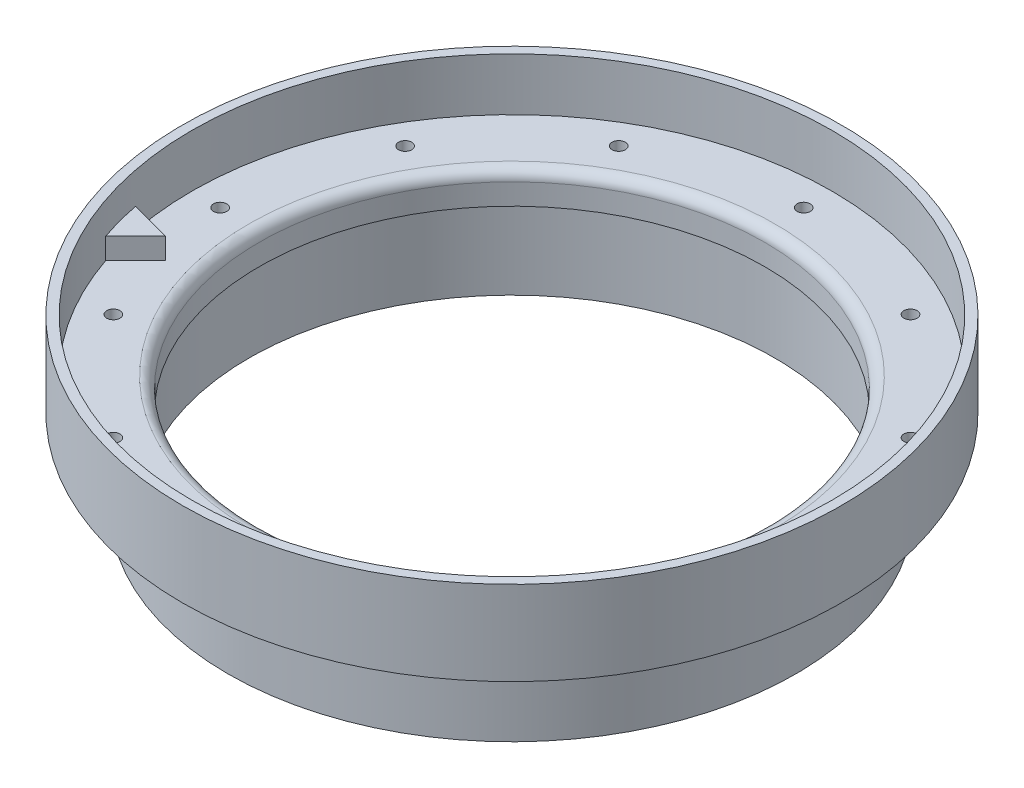
from build123d import *

# Parameters (mm, degrees)
F_3_48_TAPPED_HOLE1_D = 1.9939
CIRPATTERN1_COUNT     = 12
BOSS_EXTRUDE1_DEPTH   = 3.175


with BuildPart() as part:
    # Cross Section → Main (revolve)
    with BuildSketch(Plane.XY):
        with BuildLine():
            Line((-38.1, 0), (-38.1, -3.175))
            Line((-38.1, -3.175), (-39.6367, -3.175))
            Line((-39.6367, -3.175), (-39.6367, -15.875))
            Line((-39.6367, -15.875), (-42.8117, -15.875))
            Line((-42.8117, -15.875), (-42.8117, -3.175))
            Line((-42.8117, -3.175), (-49.6697, -3.175))
            Line((-49.6697, -3.175), (-49.6697, 9.525))
            Line((-49.6697, 9.525), (-48.26, 9.525))
            Line((-48.26, 9.525), (-48.26, 1.5875))
            Line((-48.26, 1.5875), (-39.6875, 1.5875))
            ThreePointArc((-39.6875, 1.5875), (-38.564967985, 1.122532015), (-38.1, 0))
        make_face()
    revolve(axis=Axis((0, 55, 0), (0, -1, 0)))

    # #3-48 Tapped Hole1 (through all)
    with Locations(Plane(origin=(0, 1.5875, 0), x_dir=(1, 0, 0), z_dir=(0, 1, 0))):
        with Locations((-43.97375, 0)):
            f_3_48_tapped_hole1 = Hole(F_3_48_TAPPED_HOLE1_D / 2)

    # CirPattern1: #3-48 Tapped Hole1 ×12 about axis
    cirpattern1_axis = Axis((0, 0, 0), (0, 1, 0))
    for i in range(1, CIRPATTERN1_COUNT):
        add(f_3_48_tapped_hole1.rotate(cirpattern1_axis, i * 360 / CIRPATTERN1_COUNT), mode=Mode.SUBTRACT)

    # Sketch3 → Boss-Extrude1 (add)
    with BuildSketch(Plane(origin=(0, 1.5875, 0), x_dir=(1, 0, 0), z_dir=(0, 1, 0))):
        with BuildLine():
            Line((-45.692838455, -15.530361037), (-41.202710394, -11.040232976))
            Line((-41.202710394, -11.040232976), (-47.336339391, -9.39673204))
            ThreePointArc((-47.336339391, -9.39673204), (-46.615580377, -12.490607117), (-45.692838455, -15.530361037))
        make_face()
    extrude(amount=BOSS_EXTRUDE1_DEPTH)


solid = part.part
